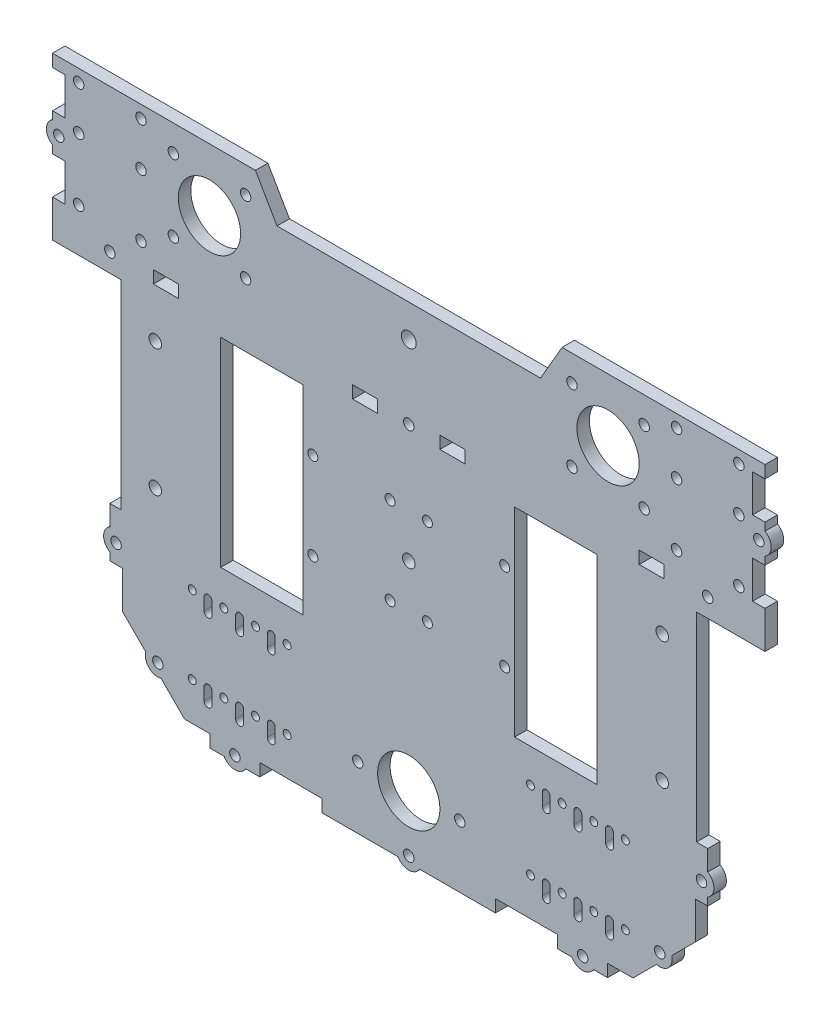
from build123d import *

# Parameters (mm, degrees)
SKETCH1_W            = 240
SKETCH1_H            = 210
BOSS_EXTRUDE1_DEPTH  = 5
SKETCH2_W            = 77.5
SKETCH2_H            = 80
CUT_EXTRUDE1_DEPTH   = 5
SKETCH3_W            = 17.5
SKETCH3_H            = 80
BOSS_EXTRUDE2_DEPTH  = 5
CUT_EXTRUDE8_DEPTH   = 5
SKETCH10_W           = 5
SKETCH10_H           = 65
BOSS_EXTRUDE3_DEPTH  = 20
SKETCH5_R            = 2.1
CUT_EXTRUDE9_DEPTH   = 10
SKETCH12_W           = 5
SKETCH12_H           = 35.2
SKETCH12_W_2         = 60.2
SKETCH12_H_2         = 5
CUT_EXTRUDE11_DEPTH  = 10
SKETCH15_R           = 2
SKETCH15_R_2         = 2.5
CUT_EXTRUDE13_DEPTH  = 10
SKETCH16_R           = 2.5
CUT_EXTRUDE14_DEPTH  = 10
SKETCH17_R           = 12.5
SKETCH17_R_2         = 2.1
CUT_EXTRUDE15_DEPTH  = 5
CUT_EXTRUDE17_DEPTH  = 10
SKETCH19_R           = 12.5
SKETCH19_R_2         = 2.1
CUT_EXTRUDE18_DEPTH  = 10
SKETCH21_W           = 5
SKETCH21_H           = 65
CUT_EXTRUDE20_DEPTH  = 3
SKETCH22_W           = 5
SKETCH22_H           = 65
CUT_EXTRUDE21_DEPTH  = 3
SKETCH23_R           = 2.1
CUT_EXTRUDE22_DEPTH  = 10
BOSS_EXTRUDE4_DEPTH  = 5
SKETCH26_W           = 20
SKETCH26_H           = 5
BOSS_EXTRUDE5_DEPTH  = 5
SKETCH27_R           = 2.1
CUT_EXTRUDE24_DEPTH  = 5
BOSS_EXTRUDE7_DEPTH  = 5
SKETCH30_W           = 5
SKETCH30_H           = 80
BOSS_EXTRUDE8_DEPTH  = 5
SKETCH31_W           = 5
SKETCH31_H           = 80
BOSS_EXTRUDE9_DEPTH  = 5
SKETCH32_R           = 2.1
CUT_EXTRUDE25_DEPTH  = 5
BOSS_EXTRUDE10_DEPTH = 5
SKETCH34_R           = 3
CUT_EXTRUDE26_DEPTH  = 5
SKETCH35_R           = 2.1
SKETCH35_W           = 10
SKETCH35_H           = 5
CUT_EXTRUDE27_DEPTH  = 5
SKETCH37_W           = 5
SKETCH37_H           = 5
BOSS_EXTRUDE11_DEPTH = 0.2
SKETCH38_W           = 5
SKETCH38_H           = 5
BOSS_EXTRUDE12_DEPTH = 0.2
SKETCH39_R           = 2.1
CUT_EXTRUDE28_DEPTH  = 5
BOSS_EXTRUDE13_DEPTH = 5
SKETCH42_R           = 1.5875
CUT_EXTRUDE29_DEPTH  = 10
SKETCH43_W           = 5
SKETCH43_H           = 65
BOSS_EXTRUDE14_DEPTH = 6
SKETCH44_W           = 5
SKETCH44_H           = 65
BOSS_EXTRUDE15_DEPTH = 6
SKETCH54_W           = 10
SKETCH54_H           = 5
CUT_EXTRUDE34_DEPTH  = 5
SKETCH56_W           = 4.979498839
SKETCH56_H           = 15
CUT_EXTRUDE36_DEPTH  = 5
SKETCH57_R           = 2.1
CUT_EXTRUDE37_DEPTH  = 10
SKETCH58_R           = 2.1
CUT_EXTRUDE38_DEPTH  = 5
BOSS_EXTRUDE21_DEPTH = 5
SKETCH60_W           = 5
SKETCH60_H           = 80
BOSS_EXTRUDE22_DEPTH = 17.5
SKETCH61_W           = 5
SKETCH61_H           = 80
BOSS_EXTRUDE23_DEPTH = 17.5
BOSS_EXTRUDE24_DEPTH = 5


with BuildPart() as part:
    # Sketch1 → Boss-Extrude1 (new body)
    with BuildSketch(Plane.XY):
        with Locations((-120, 105)):
            Rectangle(SKETCH1_W, SKETCH1_H)
    extrude(amount=BOSS_EXTRUDE1_DEPTH)

    # Sketch2 → Cut-Extrude1 (cut)
    with BuildSketch(Plane.XY.offset(5)):
        with Locations((-201.25, 105)):
            Rectangle(SKETCH2_W, SKETCH2_H)
        with Locations((-38.75, 105)):
            Rectangle(SKETCH2_W, SKETCH2_H)
    extrude(amount=-CUT_EXTRUDE1_DEPTH, mode=Mode.SUBTRACT)

    # Sketch3 → Boss-Extrude2 (add)
    with BuildSketch(Plane.XY.offset(5)):
        with Locations((-221.75, 105)):
            Rectangle(SKETCH3_W, SKETCH3_H)
        with Locations((-18.25, 105)):
            Rectangle(SKETCH3_W, SKETCH3_H)
    extrude(amount=-BOSS_EXTRUDE2_DEPTH)

    # Sketch9 → Cut-Extrude8 (cut)
    with BuildSketch(Plane(origin=(0, 0, 0), x_dir=(-1, 0, 0), z_dir=(0, 0, -1))):
        Polygon((170, 190), (220, 276.602540378), (170, 363.205080757), (70, 363.205080757), (20, 276.602540378), (70, 190), align=None)
    extrude(amount=-CUT_EXTRUDE8_DEPTH, mode=Mode.SUBTRACT)

    # Sketch10 → Boss-Extrude3 (add)
    with BuildSketch(Plane.ZY.offset(240)):
        with Locations((2.5, 177.5)):
            Rectangle(SKETCH10_W, SKETCH10_H)
    boss_extrude3 = extrude(amount=BOSS_EXTRUDE3_DEPTH)

    # Mirror2: Boss-Extrude3 across plane
    add(boss_extrude3.mirror(Plane(origin=(-120, 0, 0), x_dir=(0, 0, 1), z_dir=(1, 0, 0))))

    # Sketch5 → Cut-Extrude9 (cut)
    with BuildSketch(Plane.XY.offset(5)):
        with Locations((12.5, 187.5)):
            Circle(SKETCH5_R)
        with Locations((-12.5, 162.5)):
            Circle(SKETCH5_R)
        with Locations((-12.5, 187.5)):
            Circle(SKETCH5_R)
        with Locations((12.5, 162.5)):
            Circle(SKETCH5_R)
        with Locations((-12.5, 205)):
            Circle(SKETCH5_R)
        with Locations((12.5, 205)):
            Circle(SKETCH5_R)
    cut_extrude9 = extrude(amount=-CUT_EXTRUDE9_DEPTH, mode=Mode.SUBTRACT)

    # Mirror3: Cut-Extrude9 across plane
    add(cut_extrude9.mirror(Plane(origin=(-120, 0, 0), x_dir=(0, 0, 1), z_dir=(1, 0, 0))), mode=Mode.SUBTRACT)

    # Sketch12 → Cut-Extrude11 (cut)
    with BuildSketch(Plane.XY.offset(5)):
        with Locations((-2.5, 27.6)):
            Rectangle(SKETCH12_W, SKETCH12_H)
        with Locations((-237.5, 27.6)):
            Rectangle(SKETCH12_W, SKETCH12_H)
        with Locations((-184.9, 2.5)):
            Rectangle(SKETCH12_W_2, SKETCH12_H_2)
        with Locations((-55.1, 2.5)):
            Rectangle(SKETCH12_W_2, SKETCH12_H_2)
    extrude(amount=-CUT_EXTRUDE11_DEPTH, mode=Mode.SUBTRACT)

    # Sketch15 → Cut-Extrude13 (cut)
    with BuildSketch(Plane(origin=(0, 0, 0), x_dir=(-1, 0, 0), z_dir=(0, 0, -1))):
        with Locations((158.5, 87.5)):
            Circle(SKETCH15_R)
        with Locations((158.5, 122.5)):
            Circle(SKETCH15_R)
        with Locations((127.5, 122.5)):
            Circle(SKETCH15_R)
        with Locations((127.5, 87.5)):
            Circle(SKETCH15_R)
        with Locations((112.5, 87.5)):
            Circle(SKETCH15_R)
        with Locations((112.5, 122.5)):
            Circle(SKETCH15_R)
        with Locations((81.5, 122.5)):
            Circle(SKETCH15_R)
        with Locations((81.5, 87.5)):
            Circle(SKETCH15_R)
        with Locations((120, 105)):
            Circle(SKETCH15_R_2)
    extrude(amount=-CUT_EXTRUDE13_DEPTH, mode=Mode.SUBTRACT)

    # Sketch16 → Cut-Extrude14 (cut)
    with BuildSketch(Plane(origin=(0, 0, 0), x_dir=(-1, 0, 0), z_dir=(0, 0, -1))):
        with Locations((18.25, 130.5)):
            Circle(SKETCH16_R)
        with Locations((18.25, 79.5)):
            Circle(SKETCH16_R)
        with Locations((221.75, 79.5)):
            Circle(SKETCH16_R)
        with Locations((221.75, 130.5)):
            Circle(SKETCH16_R)
    extrude(amount=-CUT_EXTRUDE14_DEPTH, mode=Mode.SUBTRACT)

    # Sketch17 → Cut-Extrude15 (cut)
    with BuildSketch(Plane(origin=(0, 0, 0), x_dir=(-1, 0, 0), z_dir=(0, 0, -1))):
        with Locations((40, 185)):
            Circle(SKETCH17_R)
        with Locations((54.495689014, 170.504310986)):
            Circle(SKETCH17_R_2)
        with Locations((25.504310986, 199.495689014)):
            Circle(SKETCH17_R_2)
        with Locations((54.495689014, 199.495689014)):
            Circle(SKETCH17_R_2)
        with Locations((25.504310986, 170.504310986)):
            Circle(SKETCH17_R_2)
        with Locations((185.504310986, 199.495689014)):
            Circle(SKETCH17_R_2)
        with Locations((214.495689014, 170.504310986)):
            Circle(SKETCH17_R_2)
        with Locations((214.495689014, 199.495689014)):
            Circle(SKETCH17_R_2)
        with Locations((185.504310986, 170.504310986)):
            Circle(SKETCH17_R_2)
        with Locations((200, 185)):
            Circle(SKETCH17_R)
    extrude(amount=-CUT_EXTRUDE15_DEPTH, mode=Mode.SUBTRACT)

    # Sketch18 → Cut-Extrude17 (cut)
    with BuildSketch(Plane.XY.offset(5)):
        Polygon((-210, 5), (-235, 30), (-235, 10), (-240, 10), (-240, 0), (-215, 0), (-215, 5), align=None)
        Polygon((-30, 5), (-25, 5), (-25, 0), (0, 0), (0, 10), (-5, 10), (-5, 30), align=None)
    extrude(amount=-CUT_EXTRUDE17_DEPTH, mode=Mode.SUBTRACT)

    # Sketch19 → Cut-Extrude18 (cut)
    with BuildSketch(Plane(origin=(0, 0, 0), x_dir=(-1, 0, 0), z_dir=(0, 0, -1))):
        with Locations((120, 25)):
            Circle(SKETCH19_R)
        with Locations((99.5, 25)):
            Circle(SKETCH19_R_2)
        with Locations((140.5, 25)):
            Circle(SKETCH19_R_2)
    extrude(amount=-CUT_EXTRUDE18_DEPTH, mode=Mode.SUBTRACT)

    # Sketch21 → Cut-Extrude20 (cut)
    with BuildSketch(Plane.ZY.offset(260)):
        with Locations((2.5, 177.5)):
            Rectangle(SKETCH21_W, SKETCH21_H)
    extrude(amount=-CUT_EXTRUDE20_DEPTH, mode=Mode.SUBTRACT)

    # Sketch22 → Cut-Extrude21 (cut)
    with BuildSketch(Plane(origin=(20, 0, 0), x_dir=(0, 0, -1), z_dir=(1, 0, 0))):
        with Locations((-2.5, 177.5)):
            Rectangle(SKETCH22_W, SKETCH22_H)
    extrude(amount=-CUT_EXTRUDE21_DEPTH, mode=Mode.SUBTRACT)

    # Sketch23 → Cut-Extrude22 (cut)
    with BuildSketch(Plane(origin=(0, 0, 0), x_dir=(-1, 0, 0), z_dir=(0, 0, -1))):
        with Locations((120, 2.5)):
            Circle(SKETCH23_R)
    extrude(amount=-CUT_EXTRUDE22_DEPTH, mode=Mode.SUBTRACT)

    # Sketch24 → Boss-Extrude4 (add)
    with BuildSketch(Plane(origin=(0, 0, 0), x_dir=(-1, 0, 0), z_dir=(0, 0, -1))):
        with BuildLine():
            Line((124.330127019, 0), (115.669872981, 0))
            ThreePointArc((115.669872981, 0), (120, -2.5), (124.330127019, 0))
        make_face()
    extrude(amount=-BOSS_EXTRUDE4_DEPTH)

    # Sketch26 → Boss-Extrude5 (add)
    with BuildSketch(Plane.XZ.offset(-5)):
        with Locations((-50.2, 2.5)):
            Rectangle(SKETCH26_W, SKETCH26_H)
        with Locations((-189.8, 2.5)):
            Rectangle(SKETCH26_W, SKETCH26_H)
    extrude(amount=BOSS_EXTRUDE5_DEPTH)

    # Sketch27 → Cut-Extrude24 (cut)
    with BuildSketch(Plane(origin=(0, 0, 0), x_dir=(-1, 0, 0), z_dir=(0, 0, -1))):
        with Locations((50.2, 2.5)):
            Circle(SKETCH27_R)
        with Locations((189.8, 2.5)):
            Circle(SKETCH27_R)
    extrude(amount=-CUT_EXTRUDE24_DEPTH, mode=Mode.SUBTRACT)

    # Sketch29 → Boss-Extrude7 (add)
    with BuildSketch(Plane(origin=(0, 0, 0), x_dir=(-1, 0, 0), z_dir=(0, 0, -1))):
        with BuildLine():
            Line((194.130127019, 0), (185.469872981, 0))
            ThreePointArc((185.469872981, 0), (189.8, -2.5), (194.130127019, 0))
        make_face()
        with BuildLine():
            Line((45.869872981, 0), (54.530127019, 0))
            ThreePointArc((54.530127019, 0), (50.2, -2.5), (45.869872981, 0))
        make_face()
    extrude(amount=-BOSS_EXTRUDE7_DEPTH)

    # Sketch30 → Boss-Extrude8 (add)
    with BuildSketch(Plane(origin=(-9.5, 0, 0), x_dir=(0, 0, -1), z_dir=(1, 0, 0))):
        with Locations((-2.5, 105)):
            Rectangle(SKETCH30_W, SKETCH30_H)
    extrude(amount=BOSS_EXTRUDE8_DEPTH)

    # Sketch31 → Boss-Extrude9 (add)
    with BuildSketch(Plane.ZY.offset(230.5)):
        with Locations((2.5, 105)):
            Rectangle(SKETCH31_W, SKETCH31_H)
    extrude(amount=BOSS_EXTRUDE9_DEPTH)

    # Sketch32 → Cut-Extrude25 (cut)
    with BuildSketch(Plane(origin=(0, 0, 0), x_dir=(-1, 0, 0), z_dir=(0, 0, -1))):
        with Locations((19.267766953, 19.267766953)):
            Circle(SKETCH32_R)
    cut_extrude25 = extrude(amount=-CUT_EXTRUDE25_DEPTH, mode=Mode.SUBTRACT)

    # Sketch33 → Boss-Extrude10 (add)
    with BuildSketch(Plane(origin=(0, 0, 0), x_dir=(-1, 0, 0), z_dir=(0, 0, -1))):
        with BuildLine():
            Line((20.561862178, 14.438137822), (14.438137822, 20.561862178))
            ThreePointArc((14.438137822, 20.561862178), (15.732233047, 15.732233047), (20.561862178, 14.438137822))
        make_face()
    boss_extrude10 = extrude(amount=-BOSS_EXTRUDE10_DEPTH)

    # Mirror4: Cut-Extrude25, Boss-Extrude10 across plane
    add(cut_extrude25.mirror(Plane.ZY.offset(120)), mode=Mode.SUBTRACT)
    add(boss_extrude10.mirror(Plane.ZY.offset(120)))

    # Sketch34 → Cut-Extrude26 (cut)
    with BuildSketch(Plane.XY.offset(5)):
        with Locations((-120, 182)):
            Circle(SKETCH34_R)
    extrude(amount=-CUT_EXTRUDE26_DEPTH, mode=Mode.SUBTRACT)

    # Sketch35 → Cut-Extrude27 (cut)
    with BuildSketch(Plane(origin=(0, 0, 0), x_dir=(-1, 0, 0), z_dir=(0, 0, -1))):
        with Locations((120, 152.5)):
            Circle(SKETCH35_R)
        with Locations((102.5, 152.5)):
            Rectangle(SKETCH35_W, SKETCH35_H)
        with Locations((137.5, 152.5)):
            Rectangle(SKETCH35_W, SKETCH35_H)
    extrude(amount=-CUT_EXTRUDE27_DEPTH, mode=Mode.SUBTRACT)

    # Sketch37 → Boss-Extrude11 (add)
    with BuildSketch(Plane.XZ.offset(-45.2)):
        with Locations((-2.5, 2.5)):
            Rectangle(SKETCH37_W, SKETCH37_H)
    extrude(amount=BOSS_EXTRUDE11_DEPTH)

    # Sketch38 → Boss-Extrude12 (add)
    with BuildSketch(Plane.XZ.offset(-45.2)):
        with Locations((-237.5, 2.5)):
            Rectangle(SKETCH38_W, SKETCH38_H)
    extrude(amount=BOSS_EXTRUDE12_DEPTH)

    # Sketch39 → Cut-Extrude28 (cut)
    with BuildSketch(Plane(origin=(0, 0, 0), x_dir=(-1, 0, 0), z_dir=(0, 0, -1))):
        with Locations((2.5, 52.5)):
            Circle(SKETCH39_R)
        with Locations((237.5, 52.5)):
            Circle(SKETCH39_R)
    extrude(amount=-CUT_EXTRUDE28_DEPTH, mode=Mode.SUBTRACT)

    # Sketch40 → Boss-Extrude13 (add)
    with BuildSketch(Plane(origin=(0, 0, 0), x_dir=(-1, 0, 0), z_dir=(0, 0, -1))):
        with BuildLine():
            Line((0, 56.830127019), (0, 48.169872981))
            ThreePointArc((0, 48.169872981), (-2.5, 52.5), (0, 56.830127019))
        make_face()
        with BuildLine():
            Line((240, 56.830127019), (240, 48.169872981))
            ThreePointArc((240, 48.169872981), (242.5, 52.5), (240, 56.830127019))
        make_face()
    extrude(amount=-BOSS_EXTRUDE13_DEPTH)

    # Sketch42 → Cut-Extrude29 (cut)
    with BuildSketch(Plane.XY.offset(5)):
        with BuildLine():
            ThreePointArc((-63.225, 51.5), (-64.8125, 53.0875), (-66.4, 51.5))
            Line((-66.4, 51.5), (-66.4, 46.5))
            ThreePointArc((-66.4, 46.5), (-64.8125, 44.9125), (-63.225, 46.5))
            Line((-63.225, 46.5), (-63.225, 51.5))
        make_face()
        with BuildLine():
            ThreePointArc((-50.525, 51.5), (-52.1125, 53.0875), (-53.7, 51.5))
            Line((-53.7, 51.5), (-53.7, 46.5))
            ThreePointArc((-53.7, 46.5), (-52.1125, 44.9125), (-50.525, 46.5))
            Line((-50.525, 46.5), (-50.525, 51.5))
        make_face()
        with BuildLine():
            ThreePointArc((-37.825, 51.5), (-39.4125, 53.0875), (-41, 51.5))
            Line((-41, 51.5), (-41, 46.5))
            ThreePointArc((-41, 46.5), (-39.4125, 44.9125), (-37.825, 46.5))
            Line((-37.825, 46.5), (-37.825, 51.5))
        make_face()
        with BuildLine():
            ThreePointArc((-63.225, 20.25), (-64.8125, 21.8375), (-66.4, 20.25))
            Line((-66.4, 20.25), (-66.4, 15.25))
            ThreePointArc((-66.4, 15.25), (-64.8125, 13.6625), (-63.225, 15.25))
            Line((-63.225, 15.25), (-63.225, 20.25))
        make_face()
        with BuildLine():
            ThreePointArc((-50.525, 20.25), (-52.1125, 21.8375), (-53.7, 20.25))
            Line((-53.7, 20.25), (-53.7, 15.25))
            ThreePointArc((-53.7, 15.25), (-52.1125, 13.6625), (-50.525, 15.25))
            Line((-50.525, 15.25), (-50.525, 20.25))
        make_face()
        with BuildLine():
            ThreePointArc((-37.825, 20.25), (-39.4125, 21.8375), (-41, 20.25))
            Line((-41, 20.25), (-41, 15.25))
            ThreePointArc((-41, 15.25), (-39.4125, 13.6625), (-37.825, 15.25))
            Line((-37.825, 15.25), (-37.825, 20.25))
        make_face()
        with Locations((-71.1625, 20.25)):
            Circle(SKETCH42_R)
        with Locations((-58.4625, 20.25)):
            Circle(SKETCH42_R)
        with Locations((-45.7625, 20.25)):
            Circle(SKETCH42_R)
        with Locations((-33.0625, 20.25)):
            Circle(SKETCH42_R)
        with Locations((-33.0625, 51.5)):
            Circle(SKETCH42_R)
        with Locations((-45.7625, 51.5)):
            Circle(SKETCH42_R)
        with Locations((-71.1625, 51.5)):
            Circle(SKETCH42_R)
        with Locations((-58.4625, 51.5)):
            Circle(SKETCH42_R)
    cut_extrude29 = extrude(amount=-CUT_EXTRUDE29_DEPTH, mode=Mode.SUBTRACT)

    # Sketch43 → Boss-Extrude14 (add)
    with BuildSketch(Plane.ZY.offset(257)):
        with Locations((2.5, 177.5)):
            Rectangle(SKETCH43_W, SKETCH43_H)
    extrude(amount=BOSS_EXTRUDE14_DEPTH)

    # Sketch44 → Boss-Extrude15 (add)
    with BuildSketch(Plane(origin=(17, 0, 0), x_dir=(0, 0, -1), z_dir=(1, 0, 0))):
        with Locations((-2.5, 177.5)):
            Rectangle(SKETCH44_W, SKETCH44_H)
    extrude(amount=BOSS_EXTRUDE15_DEPTH)

    # Sketch54 → Cut-Extrude34 (cut)
    with BuildSketch(Plane(origin=(0, 0, 0), x_dir=(-1, 0, 0), z_dir=(0, 0, -1))):
        with Locations((22.5, 152.5)):
            Rectangle(SKETCH54_W, SKETCH54_H)
        with Locations((217.5, 152.5)):
            Rectangle(SKETCH54_W, SKETCH54_H)
    extrude(amount=-CUT_EXTRUDE34_DEPTH, mode=Mode.SUBTRACT)

    # Sketch56 → Cut-Extrude36 (cut)
    with BuildSketch(Plane(origin=(0, 0, 0), x_dir=(-1, 0, 0), z_dir=(0, 0, -1))):
        with Locations((-20.51025058, 167.5)):
            Rectangle(SKETCH56_W, SKETCH56_H)
        with Locations((-20.51025058, 197.5)):
            Rectangle(SKETCH56_W, SKETCH56_H)
    cut_extrude36 = extrude(amount=-CUT_EXTRUDE36_DEPTH, mode=Mode.SUBTRACT)

    # Mirror6: Cut-Extrude36 across plane
    add(cut_extrude36.mirror(Plane(origin=(-120, 0, 0), x_dir=(0, 0, 1), z_dir=(1, 0, 0))), mode=Mode.SUBTRACT)

    # Sketch57 → Cut-Extrude37 (cut)
    with BuildSketch(Plane(origin=(0, 0, 0), x_dir=(-1, 0, 0), z_dir=(0, 0, -1))):
        with Locations((240, 152.5)):
            Circle(SKETCH57_R)
        with Locations((0, 152.5)):
            Circle(SKETCH57_R)
    extrude(amount=-CUT_EXTRUDE37_DEPTH, mode=Mode.SUBTRACT)

    # Sketch58 → Cut-Extrude38 (cut)
    with BuildSketch(Plane.XY.offset(5)):
        with Locations((20.5, 182.5)):
            Circle(SKETCH58_R)
        with Locations((-260.5, 182.5)):
            Circle(SKETCH58_R)
    extrude(amount=-CUT_EXTRUDE38_DEPTH, mode=Mode.SUBTRACT)

    # Sketch59 → Boss-Extrude21 (add)
    with BuildSketch(Plane(origin=(0, 0, 0), x_dir=(-1, 0, 0), z_dir=(0, 0, -1))):
        with BuildLine():
            Line((263, 186.830127019), (263, 178.169872981))
            ThreePointArc((263, 178.169872981), (265.5, 182.5), (263, 186.830127019))
        make_face()
        with BuildLine():
            Line((-23, 186.830127019), (-23, 178.169872981))
            ThreePointArc((-23, 178.169872981), (-25.5, 182.5), (-23, 186.830127019))
        make_face()
    extrude(amount=-BOSS_EXTRUDE21_DEPTH)

    # Mirror7: Cut-Extrude29 across plane
    add(cut_extrude29.mirror(Plane(origin=(-120, 0, 0), x_dir=(0, 0, 1), z_dir=(1, 0, 0))), mode=Mode.SUBTRACT)

    # Sketch60 → Boss-Extrude22 (add)
    with BuildSketch(Plane.ZY.offset(27)):
        with Locations((2.5, 105)):
            Rectangle(SKETCH60_W, SKETCH60_H)
    extrude(amount=BOSS_EXTRUDE22_DEPTH)

    # Sketch61 → Boss-Extrude23 (add)
    with BuildSketch(Plane(origin=(-213, 0, 0), x_dir=(0, 0, -1), z_dir=(1, 0, 0))):
        with Locations((-2.5, 105)):
            Rectangle(SKETCH61_W, SKETCH61_H)
    extrude(amount=BOSS_EXTRUDE23_DEPTH)

    # Sketch62 → Boss-Extrude24 (add)
    with BuildSketch(Plane.XY.offset(5)):
        Polygon((-70, 190), (-170, 190), (-172.886751346, 195), (-67.113248654, 195), align=None)
    extrude(amount=-BOSS_EXTRUDE24_DEPTH)


solid = part.part
